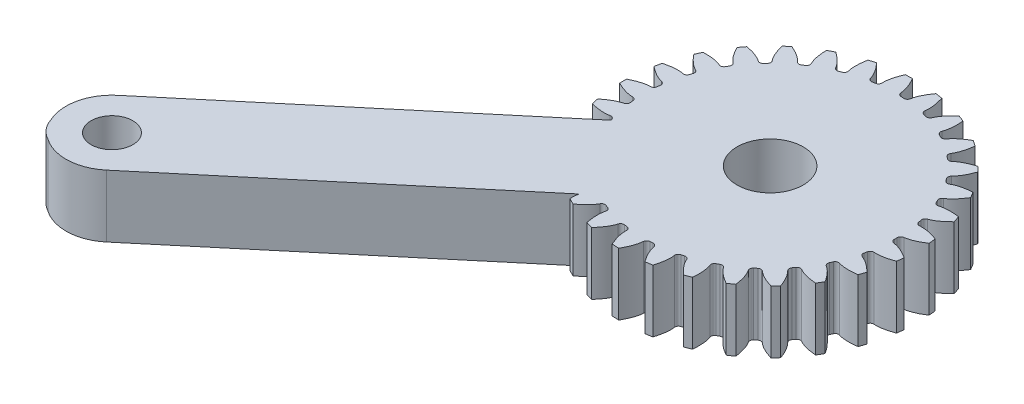
from build123d import *

# Parameters (mm, degrees)
BOSS_EXTRUDE1_DEPTH   = 5.08
CUT_EXTRUDE1_DEPTH    = 6.0800001
CUT_EXTRUDE2_DEPTH    = 6.0800001
CUT_EXTRUDE3_DEPTH    = 6.0800001
CUT_EXTRUDE4_DEPTH    = 6.0800001
CUT_EXTRUDE5_DEPTH    = 6.0800001
CUT_EXTRUDE6_DEPTH    = 6.0800001
CUT_EXTRUDE7_DEPTH    = 6.0800001
CUT_EXTRUDE8_DEPTH    = 6.0800001
CUT_EXTRUDE9_DEPTH    = 6.0800001
CUT_EXTRUDE10_DEPTH   = 6.0800001
CUT_EXTRUDE11_DEPTH   = 6.0800001
CUT_EXTRUDE12_DEPTH   = 6.0800001
CUT_EXTRUDE13_DEPTH   = 6.0800001
CUT_EXTRUDE14_DEPTH   = 6.0800001
CUT_EXTRUDE15_DEPTH   = 6.0800001
CUT_EXTRUDE16_DEPTH   = 6.0800001
CUT_EXTRUDE17_DEPTH   = 6.0800001
CUT_EXTRUDE18_DEPTH   = 6.0800001
CUT_EXTRUDE19_DEPTH   = 6.0800001
CUT_EXTRUDE20_DEPTH   = 6.0800001
CUT_EXTRUDE21_DEPTH   = 6.0800001
CUT_EXTRUDE22_DEPTH   = 6.0800001
CUT_EXTRUDE23_DEPTH   = 6.0800001
CUT_EXTRUDE24_DEPTH   = 6.0800001
CUT_EXTRUDE25_DEPTH   = 6.0800001
CUT_EXTRUDE26_DEPTH   = 6.0800001
F_3_0MM_DOWEL_HOLE1_D = 3.4
FILLET1_R             = 0.285695909
SKETCH32_R            = 2.7
CUT_EXTRUDE27_DEPTH   = 10
SKETCH33_R            = 1.7
BOSS_EXTRUDE2_DEPTH   = 5.08


with BuildPart() as part:
    # Sketch1 → Boss-Extrude1 (new body)
    with BuildSketch(Plane.XZ.offset(5.08)):
        with BuildLine():
            Line((120.988344105, 8.360112759), (98.473510803, 27.252301079))
            ThreePointArc((98.473510803, 27.252301079), (94.895077389, 26.939228722), (95.208149746, 23.360795308))
            Line((95.208149746, 23.360795308), (116.748790674, 5.28605145))
            ThreePointArc((116.748790674, 5.28605145), (116.495793982, 5.294008336), (116.242709511, 5.289662267))
            ThreePointArc((116.242709511, 5.289662267), (135.702860946, -8.243787778), (121.135707512, 10.455137454))
            add(Edge.make_bspline(
                [(121.135707512, 10.455137454), (121.152351035, 9.20992249), (121.586653527, 8.700816936)],
                knots=[1.711217129, 1.711217129, 1.711217129, 2.740480077, 2.740480077, 2.740480077], degree=2, weights=[1, 0.870474175, 1]))
            ThreePointArc((121.586653527, 8.700816936), (121.364900681, 8.558866224), (121.146868004, 8.411265138))
            ThreePointArc((121.146868004, 8.411265138), (121.071416809, 8.373879223), (120.988344105, 8.360112759))
        make_face()
    extrude(amount=-BOSS_EXTRUDE1_DEPTH)

    # Sketch2 → Cut-Extrude1 (cut, through all)
    with BuildSketch(Plane(origin=(0, 0, 0), x_dir=(-1, 0, 0), z_dir=(0, 1, 0))):
        with BuildLine():
            ThreePointArc((-115.357087959, 2.85349343), (-115.640020682, 3.827622688), (-116.004297812, 4.774343824))
            add(Edge.make_bspline(
                [(-117.42496235, 3.650642325), (-116.771119594, 3.793109057), (-116.004297812, 4.774343824)],
                knots=[3.54270523, 3.54270523, 3.54270523, 4.571968178, 4.571968178, 4.571968178], degree=2, weights=[1, 0.870474175, 1]))
            ThreePointArc((-117.42496235, 3.650642325), (-117.289049937, 3.27200004), (-117.168104319, 2.888314855))
            add(Edge.make_bspline(
                [(-115.357087959, 2.85349343), (-116.561367441, 3.170586854), (-117.168104319, 2.888314855)],
                knots=[4.852809783, 4.852809783, 4.852809783, 5.882072731, 5.882072731, 5.882072731], degree=2, weights=[1, 0.870474175, 1]))
        make_face()
    extrude(amount=-CUT_EXTRUDE1_DEPTH, mode=Mode.SUBTRACT)

    # Sketch3 → Cut-Extrude2 (cut, through all)
    with BuildSketch(Plane(origin=(0, 0, 0), x_dir=(-1, 0, 0), z_dir=(0, 1, 0))):
        with BuildLine():
            ThreePointArc((-115.015876033, 0.283898413), (-115.082784951, 1.296075242), (-115.235028425, 2.298971379))
            add(Edge.make_bspline(
                [(-116.864041222, 1.506942278), (-116.194858809, 1.505521352), (-115.235028425, 2.298971379)],
                knots=[0.401112576, 0.401112576, 0.401112576, 1.430375524, 1.430375524, 1.430375524], degree=2, weights=[1, 0.870474175, 1]))
            ThreePointArc((-116.864041222, 1.506942278), (-116.812703264, 1.107935288), (-116.777066261, 0.707220716))
            add(Edge.make_bspline(
                [(-115.015876033, 0.283898413), (-116.123834418, 0.852462859), (-116.777066261, 0.707220716)],
                knots=[4.852809783, 4.852809783, 4.852809783, 5.882072731, 5.882072731, 5.882072731], degree=2, weights=[1, 0.870474175, 1]))
        make_face()
    extrude(amount=-CUT_EXTRUDE2_DEPTH, mode=Mode.SUBTRACT)

    # Sketch4 → Cut-Extrude3 (cut, through all)
    with BuildSketch(Plane(origin=(0, 0, 0), x_dir=(-1, 0, 0), z_dir=(0, 1, 0))):
        with BuildLine():
            ThreePointArc((-115.235028425, -2.298971379), (-115.082784951, -1.296075242), (-115.015876033, -0.283898413))
            add(Edge.make_bspline(
                [(-116.777066261, -0.707220716), (-116.123834418, -0.852462859), (-115.015876033, -0.283898413)],
                knots=[0.401112576, 0.401112576, 0.401112576, 1.430375524, 1.430375524, 1.430375524], degree=2, weights=[1, 0.870474175, 1]))
            ThreePointArc((-116.777066261, -0.707220716), (-116.812703264, -1.107935288), (-116.864041222, -1.506942278))
            add(Edge.make_bspline(
                [(-115.235028425, -2.298971379), (-116.194858809, -1.505521352), (-116.864041222, -1.506942278)],
                knots=[4.852809783, 4.852809783, 4.852809783, 5.882072731, 5.882072731, 5.882072731], degree=2, weights=[1, 0.870474175, 1]))
        make_face()
    extrude(amount=-CUT_EXTRUDE3_DEPTH, mode=Mode.SUBTRACT)

    # Sketch5 → Cut-Extrude4 (cut, through all)
    with BuildSketch(Plane(origin=(0, 0, 0), x_dir=(-1, 0, 0), z_dir=(0, 1, 0))):
        with BuildLine():
            ThreePointArc((-116.004297812, -4.774343824), (-115.640020682, -3.827622688), (-115.357087959, -2.85349343))
            add(Edge.make_bspline(
                [(-117.168104319, -2.888314855), (-116.561367441, -3.170586854), (-115.357087959, -2.85349343)],
                knots=[0.401112576, 0.401112576, 0.401112576, 1.430375524, 1.430375524, 1.430375524], degree=2, weights=[1, 0.870474175, 1]))
            ThreePointArc((-117.168104319, -2.888314855), (-117.289049937, -3.27200004), (-117.42496235, -3.650642325))
            add(Edge.make_bspline(
                [(-116.004297812, -4.774343824), (-116.771119594, -3.793109057), (-117.42496235, -3.650642325)],
                knots=[1.711217129, 1.711217129, 1.711217129, 2.740480077, 2.740480077, 2.740480077], degree=2, weights=[1, 0.870474175, 1]))
        make_face()
    extrude(amount=-CUT_EXTRUDE4_DEPTH, mode=Mode.SUBTRACT)

    # Sketch6 → Cut-Extrude5 (cut, through all)
    with BuildSketch(Plane(origin=(0, 0, 0), x_dir=(-1, 0, 0), z_dir=(0, 1, 0))):
        with BuildLine():
            ThreePointArc((-117.287714012, -7.026473259), (-116.728436419, -6.180194752), (-116.242709511, -5.289662267))
            add(Edge.make_bspline(
                [(-118.018870892, -4.934354601), (-117.486999322, -5.340457732), (-116.242709511, -5.289662267)],
                knots=[0.401112576, 0.401112576, 0.401112576, 1.430375524, 1.430375524, 1.430375524], degree=2, weights=[1, 0.870474175, 1]))
            ThreePointArc((-118.018870892, -4.934354601), (-118.219469842, -5.283069707), (-118.433601597, -5.623642395))
            add(Edge.make_bspline(
                [(-117.287714012, -7.026473259), (-117.825671457, -5.903335199), (-118.433601597, -5.623642395)],
                knots=[1.711217129, 1.711217129, 1.711217129, 2.740480077, 2.740480077, 2.740480077], degree=2, weights=[1, 0.870474175, 1]))
        make_face()
    extrude(amount=-CUT_EXTRUDE5_DEPTH, mode=Mode.SUBTRACT)

    # Sketch7 → Cut-Extrude6 (cut, through all)
    with BuildSketch(Plane(origin=(0, 0, 0), x_dir=(-1, 0, 0), z_dir=(0, 1, 0))):
        with BuildLine():
            ThreePointArc((-119.025265911, -8.950052613), (-118.297139054, -8.243787777), (-117.631330011, -7.478492374))
            add(Edge.make_bspline(
                [(-119.289585081, -6.74966941), (-118.857448541, -7.260614741), (-117.631330011, -7.478492374)],
                knots=[0.401112576, 0.401112576, 0.401112576, 1.430375524, 1.430375524, 1.430375524], degree=2, weights=[1, 0.870474175, 1]))
            ThreePointArc((-119.289585081, -6.74966941), (-119.560457579, -7.047108907), (-119.842796113, -7.333687197))
            add(Edge.make_bspline(
                [(-119.025265911, -8.950052613), (-119.309204727, -7.737527949), (-119.842796113, -7.333687197)],
                knots=[1.711217129, 1.711217129, 1.711217129, 2.740480077, 2.740480077, 2.740480077], degree=2, weights=[1, 0.870474175, 1]))
        make_face()
    extrude(amount=-CUT_EXTRUDE6_DEPTH, mode=Mode.SUBTRACT)

    # Sketch8 → Cut-Extrude7 (cut, through all)
    with BuildSketch(Plane(origin=(0, 0, 0), x_dir=(-1, 0, 0), z_dir=(0, 1, 0))):
        with BuildLine():
            ThreePointArc((-121.135707512, -10.455137454), (-120.272777795, -9.921910449), (-119.458019107, -9.31763649))
            add(Edge.make_bspline(
                [(-120.920829701, -8.24937718), (-120.608634416, -8.841273475), (-119.458019107, -9.31763649)],
                knots=[0.401112577, 0.401112577, 0.401112577, 1.430375524, 1.430375524, 1.430375524], degree=2, weights=[1, 0.870474175, 1]))
            ThreePointArc((-120.920829701, -8.24937718), (-121.24931005, -8.481633126), (-121.586653527, -8.700816936))
            add(Edge.make_bspline(
                [(-121.135707512, -10.455137454), (-121.152351035, -9.20992249), (-121.586653527, -8.700816936)],
                knots=[1.711217129, 1.711217129, 1.711217129, 2.740480077, 2.740480077, 2.740480077], degree=2, weights=[1, 0.870474175, 1]))
        make_face()
    extrude(amount=-CUT_EXTRUDE7_DEPTH, mode=Mode.SUBTRACT)

    # Sketch9 → Cut-Extrude8 (cut, through all)
    with BuildSketch(Plane(origin=(0, 0, 0), x_dir=(-1, 0, 0), z_dir=(0, 1, 0))):
        with BuildLine():
            ThreePointArc((-123.520356913, -11.471351688), (-122.562973968, -11.136095615), (-121.637362847, -10.72109828))
            add(Edge.make_bspline(
                [(-122.836329568, -9.363353241), (-122.658673443, -10.008524088), (-121.637362847, -10.72109828)],
                knots=[0.401112577, 0.401112577, 0.401112577, 1.430375524, 1.430375524, 1.430375524], degree=2, weights=[1, 0.870474175, 1]))
            ThreePointArc((-122.836329568, -9.363353241), (-123.207058392, -9.519565607), (-123.583633006, -9.661106145))
            add(Edge.make_bspline(
                [(-123.520356913, -11.471351688), (-123.268926911, -10.251671293), (-123.583633006, -9.661106145)],
                knots=[1.711217129, 1.711217129, 1.711217129, 2.740480077, 2.740480077, 2.740480077], degree=2, weights=[1, 0.870474175, 1]))
        make_face()
    extrude(amount=-CUT_EXTRUDE8_DEPTH, mode=Mode.SUBTRACT)

    # Sketch10 → Cut-Extrude9 (cut, through all)
    with BuildSketch(Plane(origin=(0, 0, 0), x_dir=(-1, 0, 0), z_dir=(0, 1, 0))):
        with BuildLine():
            ThreePointArc((-126.067710557, -11.951178266), (-125.060640548, -11.829569328), (-124.06745754, -11.623253429))
            add(Edge.make_bspline(
                [(-124.946518037, -10.039509311), (-124.911708074, -10.707787237), (-124.06745754, -11.623253429)],
                knots=[0.401112576, 0.401112576, 0.401112576, 1.430375524, 1.430375524, 1.430375524], degree=2, weights=[1, 0.870474175, 1]))
            ThreePointArc((-124.946518037, -10.039509311), (-125.342160468, -10.11237378), (-125.740358009, -10.169652769))
            add(Edge.make_bspline(
                [(-126.067710557, -11.951178266), (-125.559963617, -10.814063339), (-125.740358009, -10.169652769)],
                knots=[1.711217129, 1.711217129, 1.711217129, 2.740480077, 2.740480077, 2.740480077], degree=2, weights=[1, 0.870474175, 1]))
        make_face()
    extrude(amount=-CUT_EXTRUDE9_DEPTH, mode=Mode.SUBTRACT)

    # Sketch11 → Cut-Extrude10 (cut, through all)
    with BuildSketch(Plane(origin=(0, 0, 0), x_dir=(-1, 0, 0), z_dir=(0, 1, 0))):
        with BuildLine():
            ThreePointArc((-128.658657019, -11.872181032), (-127.64898942, -11.969905526), (-126.634674659, -11.981918167))
            add(Edge.make_bspline(
                [(-127.15272504, -10.246229084), (-127.262388915, -10.906366157), (-126.634674659, -11.981918167)],
                knots=[0.401112576, 0.401112576, 0.401112576, 1.430375524, 1.430375524, 1.430375524], degree=2, weights=[1, 0.870474175, 1]))
            ThreePointArc((-127.15272504, -10.246229084), (-127.554781278, -10.232338595), (-127.955982471, -10.202677732))
            add(Edge.make_bspline(
                [(-128.658657019, -11.872181032), (-127.918334824, -10.870801803), (-127.955982471, -10.202677732)],
                knots=[1.711217129, 1.711217129, 1.711217129, 2.740480077, 2.740480077, 2.740480077], degree=2, weights=[1, 0.870474175, 1]))
        make_face()
    extrude(amount=-CUT_EXTRUDE10_DEPTH, mode=Mode.SUBTRACT)

    # Sketch12 → Cut-Extrude11 (cut, through all)
    with BuildSketch(Plane(origin=(0, 0, 0), x_dir=(-1, 0, 0), z_dir=(0, 1, 0))):
        with BuildLine():
            ThreePointArc((-131.172046522, -11.238053807), (-130.206992268, -11.550542245), (-129.218973986, -11.780321728))
            add(Edge.make_bspline(
                [(-129.351790791, -9.973846573), (-129.600800742, -10.594975516), (-129.218973986, -11.780321728)],
                knots=[0.401112576, 0.401112576, 0.401112576, 1.430375524, 1.430375524, 1.430375524], degree=2, weights=[1, 0.870474175, 1]))
            ThreePointArc((-129.351790791, -9.973846573), (-129.741461132, -9.873850629), (-130.126906256, -9.758636823))
            add(Edge.make_bspline(
                [(-131.172046522, -11.238053807), (-130.233765715, -10.419233657), (-130.126906256, -9.758636823)],
                knots=[1.711217129, 1.711217129, 1.711217129, 2.740480077, 2.740480077, 2.740480077], degree=2, weights=[1, 0.870474175, 1]))
        make_face()
    extrude(amount=-CUT_EXTRUDE11_DEPTH, mode=Mode.SUBTRACT)

    # Sketch13 → Cut-Extrude12 (cut, through all)
    with BuildSketch(Plane(origin=(0, 0, 0), x_dir=(-1, 0, 0), z_dir=(0, 1, 0))):
        with BuildLine():
            ThreePointArc((-133.490355767, -10.078447677), (-132.615039722, -10.591088446), (-131.699516555, -11.027890538))
            add(Edge.make_bspline(
                [(-131.440889417, -9.235098081), (-131.817602016, -9.788175596), (-131.699516555, -11.027890538)],
                knots=[0.401112576, 0.401112576, 0.401112576, 1.430375524, 1.430375524, 1.430375524], degree=2, weights=[1, 0.870474175, 1]))
            ThreePointArc((-131.440889417, -9.235098081), (-131.799953311, -9.053672382), (-132.151619379, -8.858292903))
            add(Edge.make_bspline(
                [(-133.490355767, -10.078447677), (-132.397989315, -9.480473725), (-132.151619379, -8.858292903)],
                knots=[1.711217129, 1.711217129, 1.711217129, 2.740480077, 2.740480077, 2.740480077], degree=2, weights=[1, 0.870474175, 1]))
        make_face()
    extrude(amount=-CUT_EXTRUDE12_DEPTH, mode=Mode.SUBTRACT)

    # Sketch14 → Cut-Extrude13 (cut, through all)
    with BuildSketch(Plane(origin=(0, 0, 0), x_dir=(-1, 0, 0), z_dir=(0, 1, 0))):
        with BuildLine():
            ThreePointArc((-135.50518319, -8.447584535), (-134.760534159, -9.136407123), (-133.960314953, -9.759807443))
            add(Edge.make_bspline(
                [(-133.32233699, -8.064526667), (-133.809137575, -8.523691464), (-133.960314953, -9.759807443)],
                knots=[0.401112576, 0.401112576, 0.401112576, 1.430375524, 1.430375524, 1.430375524], degree=2, weights=[1, 0.870474175, 1]))
            ThreePointArc((-133.32233699, -8.064526667), (-133.634005007, -7.810154476), (-133.935448505, -7.543745052))
            add(Edge.make_bspline(
                [(-135.50518319, -8.447584535), (-134.309808935, -8.098417378), (-133.935448505, -7.543745052)],
                knots=[1.711217129, 1.711217129, 1.711217129, 2.740480077, 2.740480077, 2.740480077], degree=2, weights=[1, 0.870474175, 1]))
        make_face()
    extrude(amount=-CUT_EXTRUDE13_DEPTH, mode=Mode.SUBTRACT)

    # Sketch15 → Cut-Extrude14 (cut, through all)
    with BuildSketch(Plane(origin=(0, 0, 0), x_dir=(-1, 0, 0), z_dir=(0, 1, 0))):
        with BuildLine():
            ThreePointArc((-137.122317699, -6.421721728), (-136.543154645, -7.254517557), (-135.895656759, -8.035366599))
            add(Edge.make_bspline(
                [(-134.908159112, -6.516866949), (-135.482285429, -6.860648992), (-135.895656759, -8.035366599)],
                knots=[0.401112576, 0.401112576, 0.401112576, 1.430375524, 1.430375524, 1.430375524], degree=2, weights=[1, 0.870474175, 1]))
            ThreePointArc((-134.908159112, -6.516866949), (-135.157858003, -6.201442428), (-135.394983768, -5.876460066))
            add(Edge.make_bspline(
                [(-137.122317699, -6.421721728), (-135.879830013, -6.337688035), (-135.394983768, -5.876460066)],
                knots=[1.711217129, 1.711217129, 1.711217129, 2.740480077, 2.740480077, 2.740480077], degree=2, weights=[1, 0.870474175, 1]))
        make_face()
    extrude(amount=-CUT_EXTRUDE14_DEPTH, mode=Mode.SUBTRACT)

    # Sketch16 → Cut-Extrude15 (cut, through all)
    with BuildSketch(Plane(origin=(0, 0, 0), x_dir=(-1, 0, 0), z_dir=(0, 1, 0))):
        with BuildLine():
            ThreePointArc((-138.266143883, -4.095586351), (-137.879547825, -5.033414813), (-137.415047543, -5.935200944))
            add(Edge.make_bspline(
                [(-136.124204504, -4.664485776), (-136.758811043, -4.876810199), (-137.415047543, -5.935200944)],
                knots=[0.401112576, 0.401112576, 0.401112576, 1.430375524, 1.430375524, 1.430375524], degree=2, weights=[1, 0.870474175, 1]))
            ThreePointArc((-136.124204504, -4.664485776), (-136.300258625, -4.302757824), (-136.46197892, -3.934398339))
            add(Edge.make_bspline(
                [(-138.266143883, -4.095586351), (-137.034640109, -4.280615444), (-136.46197892, -3.934398339)],
                knots=[1.711217129, 1.711217129, 1.711217129, 2.740480077, 2.740480077, 2.740480077], degree=2, weights=[1, 0.870474175, 1]))
        make_face()
    extrude(amount=-CUT_EXTRUDE15_DEPTH, mode=Mode.SUBTRACT)

    # Sketch17 → Cut-Extrude16 (cut, through all)
    with BuildSketch(Plane(origin=(0, 0, 0), x_dir=(-1, 0, 0), z_dir=(0, 1, 0))):
        with BuildLine():
            ThreePointArc((-138.883177701, -1.577945908), (-138.707225441, -2.576955187), (-138.447442279, -3.557511889))
            add(Edge.make_bspline(
                [(-136.913612234, -2.593998431), (-137.579025499, -2.664937181), (-138.447442279, -3.557511889)],
                knots=[0.401112576, 0.401112576, 0.401112576, 1.430375524, 1.430375524, 1.430375524], degree=2, weights=[1, 0.870474175, 1]))
            ThreePointArc((-136.913612234, -2.593998431), (-137.00778949, -2.202881047), (-137.086542454, -1.808368519))
            add(Edge.make_bspline(
                [(-138.883177701, -1.577945908), (-137.720241586, -2.023386032), (-137.086542454, -1.808368519)],
                knots=[1.711217129, 1.711217129, 1.711217129, 2.740480077, 2.740480077, 2.740480077], degree=2, weights=[1, 0.870474175, 1]))
        make_face()
    extrude(amount=-CUT_EXTRUDE16_DEPTH, mode=Mode.SUBTRACT)

    # Sketch18 → Cut-Extrude17 (cut, through all)
    with BuildSketch(Plane(origin=(0, 0, 0), x_dir=(-1, 0, 0), z_dir=(0, 1, 0))):
        with BuildLine():
            ThreePointArc((-138.944567336, 1.013477532), (-138.987486207, 0), (-138.944567336, -1.013477532))
            add(Edge.make_bspline(
                [(-137.239470473, -0.402218604), (-137.904576481, -0.328454662), (-138.944567336, -1.013477532)],
                knots=[3.54270523, 3.54270523, 3.54270523, 4.571968178, 4.571968178, 4.571968178], degree=2, weights=[1, 0.870474175, 1]))
            ThreePointArc((-137.239470473, -0.402218604), (-137.247367241, 0), (-137.239470473, 0.402218604))
            add(Edge.make_bspline(
                [(-138.944567336, 1.013477532), (-137.904576481, 0.328454662), (-137.239470473, 0.402218604)],
                knots=[1.711217129, 1.711217129, 1.711217129, 2.740480077, 2.740480077, 2.740480077], degree=2, weights=[1, 0.870474175, 1]))
        make_face()
    extrude(amount=-CUT_EXTRUDE17_DEPTH, mode=Mode.SUBTRACT)

    # Sketch19 → Cut-Extrude18 (cut, through all)
    with BuildSketch(Plane(origin=(0, 0, 0), x_dir=(-1, 0, 0), z_dir=(0, 1, 0))):
        with BuildLine():
            ThreePointArc((-138.447442279, 3.557511889), (-138.707225441, 2.576955187), (-138.883177701, 1.577945908))
            add(Edge.make_bspline(
                [(-137.086542454, 1.808368519), (-137.720241586, 2.023386032), (-138.883177701, 1.577945908)],
                knots=[3.54270523, 3.54270523, 3.54270523, 4.571968178, 4.571968178, 4.571968178], degree=2, weights=[1, 0.870474175, 1]))
            ThreePointArc((-137.086542454, 1.808368519), (-137.00778949, 2.202881047), (-136.913612234, 2.593998431))
            add(Edge.make_bspline(
                [(-138.447442279, 3.557511889), (-137.579025499, 2.664937181), (-136.913612234, 2.593998431)],
                knots=[4.852809783, 4.852809783, 4.852809783, 5.882072731, 5.882072731, 5.882072731], degree=2, weights=[1, 0.870474175, 1]))
        make_face()
    extrude(amount=-CUT_EXTRUDE18_DEPTH, mode=Mode.SUBTRACT)

    # Sketch20 → Cut-Extrude19 (cut, through all)
    with BuildSketch(Plane(origin=(0, 0, 0), x_dir=(-1, 0, 0), z_dir=(0, 1, 0))):
        with BuildLine():
            ThreePointArc((-137.415047543, 5.935200944), (-137.879547825, 5.033414813), (-138.266143883, 4.095586351))
            add(Edge.make_bspline(
                [(-136.46197892, 3.934398339), (-137.034640109, 4.280615444), (-138.266143883, 4.095586351)],
                knots=[3.54270523, 3.54270523, 3.54270523, 4.571968178, 4.571968178, 4.571968178], degree=2, weights=[1, 0.870474175, 1]))
            ThreePointArc((-136.46197892, 3.934398339), (-136.300258625, 4.302757824), (-136.124204504, 4.664485776))
            add(Edge.make_bspline(
                [(-137.415047543, 5.935200944), (-136.758811043, 4.876810199), (-136.124204504, 4.664485776)],
                knots=[4.852809783, 4.852809783, 4.852809783, 5.882072731, 5.882072731, 5.882072731], degree=2, weights=[1, 0.870474175, 1]))
        make_face()
    extrude(amount=-CUT_EXTRUDE19_DEPTH, mode=Mode.SUBTRACT)

    # Sketch21 → Cut-Extrude20 (cut, through all)
    with BuildSketch(Plane(origin=(0, 0, 0), x_dir=(-1, 0, 0), z_dir=(0, 1, 0))):
        with BuildLine():
            ThreePointArc((-135.895656759, 8.035366599), (-136.543154645, 7.254517557), (-137.122317699, 6.421721728))
            add(Edge.make_bspline(
                [(-135.394983768, 5.876460066), (-135.879830013, 6.337688035), (-137.122317699, 6.421721728)],
                knots=[3.54270523, 3.54270523, 3.54270523, 4.571968178, 4.571968178, 4.571968178], degree=2, weights=[1, 0.870474175, 1]))
            ThreePointArc((-135.394983768, 5.876460066), (-135.157858003, 6.201442428), (-134.908159112, 6.516866949))
            add(Edge.make_bspline(
                [(-135.895656759, 8.035366599), (-135.482285429, 6.860648992), (-134.908159112, 6.516866949)],
                knots=[4.852809783, 4.852809783, 4.852809783, 5.882072731, 5.882072731, 5.882072731], degree=2, weights=[1, 0.870474175, 1]))
        make_face()
    extrude(amount=-CUT_EXTRUDE20_DEPTH, mode=Mode.SUBTRACT)

    # Sketch22 → Cut-Extrude21 (cut, through all)
    with BuildSketch(Plane(origin=(0, 0, 0), x_dir=(-1, 0, 0), z_dir=(0, 1, 0))):
        with BuildLine():
            ThreePointArc((-133.960314953, 9.759807443), (-134.760534159, 9.136407123), (-135.50518319, 8.447584535))
            add(Edge.make_bspline(
                [(-133.935448505, 7.543745052), (-134.309808935, 8.098417378), (-135.50518319, 8.447584535)],
                knots=[3.54270523, 3.54270523, 3.54270523, 4.571968178, 4.571968178, 4.571968178], degree=2, weights=[1, 0.870474175, 1]))
            ThreePointArc((-133.935448505, 7.543745052), (-133.634005007, 7.810154476), (-133.32233699, 8.064526667))
            add(Edge.make_bspline(
                [(-133.960314953, 9.759807443), (-133.809137575, 8.523691464), (-133.32233699, 8.064526667)],
                knots=[4.852809783, 4.852809783, 4.852809783, 5.882072731, 5.882072731, 5.882072731], degree=2, weights=[1, 0.870474175, 1]))
        make_face()
    extrude(amount=-CUT_EXTRUDE21_DEPTH, mode=Mode.SUBTRACT)

    # Sketch23 → Cut-Extrude22 (cut, through all)
    with BuildSketch(Plane(origin=(0, 0, 0), x_dir=(-1, 0, 0), z_dir=(0, 1, 0))):
        with BuildLine():
            ThreePointArc((-131.699516555, 11.027890538), (-132.615039722, 10.591088446), (-133.490355767, 10.078447677))
            add(Edge.make_bspline(
                [(-132.151619379, 8.858292903), (-132.397989315, 9.480473725), (-133.490355767, 10.078447677)],
                knots=[3.54270523, 3.54270523, 3.54270523, 4.571968178, 4.571968178, 4.571968178], degree=2, weights=[1, 0.870474175, 1]))
            ThreePointArc((-132.151619379, 8.858292903), (-131.799953311, 9.053672382), (-131.440889417, 9.235098081))
            add(Edge.make_bspline(
                [(-131.699516555, 11.027890538), (-131.817602016, 9.788175596), (-131.440889417, 9.235098081)],
                knots=[4.852809783, 4.852809783, 4.852809783, 5.882072731, 5.882072731, 5.882072731], degree=2, weights=[1, 0.870474175, 1]))
        make_face()
    extrude(amount=-CUT_EXTRUDE22_DEPTH, mode=Mode.SUBTRACT)

    # Sketch24 → Cut-Extrude23 (cut, through all)
    with BuildSketch(Plane(origin=(0, 0, 0), x_dir=(-1, 0, 0), z_dir=(0, 1, 0))):
        with BuildLine():
            ThreePointArc((-129.218973986, 11.780321728), (-130.206992268, 11.550542245), (-131.172046522, 11.238053807))
            add(Edge.make_bspline(
                [(-130.126906256, 9.758636823), (-130.233765715, 10.419233657), (-131.172046522, 11.238053807)],
                knots=[3.54270523, 3.54270523, 3.54270523, 4.571968178, 4.571968178, 4.571968178], degree=2, weights=[1, 0.870474175, 1]))
            ThreePointArc((-130.126906256, 9.758636823), (-129.741461132, 9.873850629), (-129.351790791, 9.973846573))
            add(Edge.make_bspline(
                [(-129.218973986, 11.780321728), (-129.600800742, 10.594975516), (-129.351790791, 9.973846573)],
                knots=[4.852809783, 4.852809783, 4.852809783, 5.882072731, 5.882072731, 5.882072731], degree=2, weights=[1, 0.870474175, 1]))
        make_face()
    extrude(amount=-CUT_EXTRUDE23_DEPTH, mode=Mode.SUBTRACT)

    # Sketch25 → Cut-Extrude24 (cut, through all)
    with BuildSketch(Plane(origin=(0, 0, 0), x_dir=(-1, 0, 0), z_dir=(0, 1, 0))):
        with BuildLine():
            ThreePointArc((-126.634674659, 11.981918167), (-127.64898942, 11.969905526), (-128.658657019, 11.872181032))
            add(Edge.make_bspline(
                [(-127.955982471, 10.202677732), (-127.918334824, 10.870801803), (-128.658657019, 11.872181032)],
                knots=[3.54270523, 3.54270523, 3.54270523, 4.571968178, 4.571968178, 4.571968178], degree=2, weights=[1, 0.870474175, 1]))
            ThreePointArc((-127.955982471, 10.202677732), (-127.554781278, 10.232338595), (-127.15272504, 10.246229084))
            add(Edge.make_bspline(
                [(-126.634674659, 11.981918167), (-127.262388915, 10.906366157), (-127.15272504, 10.246229084)],
                knots=[4.852809783, 4.852809783, 4.852809783, 5.882072731, 5.882072731, 5.882072731], degree=2, weights=[1, 0.870474175, 1]))
        make_face()
    extrude(amount=-CUT_EXTRUDE24_DEPTH, mode=Mode.SUBTRACT)

    # Sketch26 → Cut-Extrude25 (cut, through all)
    with BuildSketch(Plane(origin=(0, 0, 0), x_dir=(-1, 0, 0), z_dir=(0, 1, 0))):
        with BuildLine():
            ThreePointArc((-124.06745754, 11.623253429), (-125.060640548, 11.829569328), (-126.067710557, 11.951178266))
            add(Edge.make_bspline(
                [(-125.740358009, 10.169652769), (-125.559963617, 10.814063339), (-126.067710557, 11.951178266)],
                knots=[3.54270523, 3.54270523, 3.54270523, 4.571968178, 4.571968178, 4.571968178], degree=2, weights=[1, 0.870474175, 1]))
            ThreePointArc((-125.740358009, 10.169652769), (-125.342160468, 10.11237378), (-124.946518037, 10.039509311))
            add(Edge.make_bspline(
                [(-124.06745754, 11.623253429), (-124.911708074, 10.707787237), (-124.946518037, 10.039509311)],
                knots=[4.852809783, 4.852809783, 4.852809783, 5.882072731, 5.882072731, 5.882072731], degree=2, weights=[1, 0.870474175, 1]))
        make_face()
    extrude(amount=-CUT_EXTRUDE25_DEPTH, mode=Mode.SUBTRACT)

    # Sketch27 → Cut-Extrude26 (cut, through all)
    with BuildSketch(Plane(origin=(0, 0, 0), x_dir=(-1, 0, 0), z_dir=(0, 1, 0))):
        with BuildLine():
            ThreePointArc((-121.637362847, 10.72109828), (-122.562973968, 11.136095615), (-123.520356913, 11.471351688))
            add(Edge.make_bspline(
                [(-123.583633006, 9.661106145), (-123.268926911, 10.251671293), (-123.520356913, 11.471351688)],
                knots=[3.54270523, 3.54270523, 3.54270523, 4.571968178, 4.571968178, 4.571968178], degree=2, weights=[1, 0.870474175, 1]))
            ThreePointArc((-123.583633006, 9.661106145), (-123.207058392, 9.519565607), (-122.836329568, 9.363353241))
            add(Edge.make_bspline(
                [(-121.637362847, 10.72109828), (-122.658673442, 10.008524088), (-122.836329568, 9.363353241)],
                knots=[4.852809783, 4.852809783, 4.852809783, 5.882072731, 5.882072731, 5.882072731], degree=2, weights=[1, 0.870474175, 1]))
        make_face()
    extrude(amount=-CUT_EXTRUDE26_DEPTH, mode=Mode.SUBTRACT)

    # Ø3.0mm Dowel Hole1 (through all)
    with Locations(Plane(origin=(0, -5.08, 0), x_dir=(-1, 0, 0), z_dir=(0, -1, 0))):
        with Locations((-97.813706717, -24.490207929)):
            Hole(F_3_0MM_DOWEL_HOLE1_D / 2)

    # Fillet1
    fillet1_edges = [part.edges().sort_by_distance(p)[0] for p in [
        (116.777066261, -2.54, 0.707220716),
        (131.440889417, -2.54, 9.235098081),
        (136.913612234, -2.54, 2.593998431),
        (137.239470473, -2.54, 0.402218604),
        (117.42496235, -2.54, -3.650642325),
        (122.836329568, -2.54, -9.363353241),
        (122.836329568, -2.54, 9.363353241),
        (123.583633006, -2.54, -9.661106145),
        (133.32233699, -2.54, 8.064526667),
        (120.920829701, -2.54, -8.24937718),
        (127.15272504, -2.54, 10.246229084),
        (121.586653527, -2.54, -8.700816936),
        (116.864041222, -2.54, -1.506942278),
        (118.018870892, -2.54, -4.934354601),
        (117.168104319, -2.54, 2.888314855),
        (118.433601597, -2.54, -5.623642395),
        (119.289585081, -2.54, -6.74966941),
        (136.124204504, -2.54, 4.664485776),
        (119.842796113, -2.54, -7.333687197),
        (134.908159112, -2.54, 6.516866949),
        (124.946518037, -2.54, -10.039509311),
        (129.351790791, -2.54, 9.973846573),
        (125.740358009, -2.54, -10.169652769),
        (124.946518037, -2.54, 10.039509311),
        (127.15272504, -2.54, -10.246229084),
        (116.777066261, -2.54, -0.707220716),
        (127.955982471, -2.54, -10.202677732),
        (116.864041222, -2.54, 1.506942278),
        (129.351790791, -2.54, -9.973846573),
        (117.42496235, -2.54, 3.650642325),
        (130.126906256, -2.54, -9.758636823),
        (123.583633006, -2.54, 9.661106145),
        (131.440889417, -2.54, -9.235098081),
        (121.586653527, -2.54, 8.700816936),
        (132.151619379, -2.54, -8.858292903),
        (137.086542454, -2.54, 1.808368519),
        (134.908159112, -2.54, -6.516866949),
        (136.46197892, -2.54, 3.934398339),
        (135.394983768, -2.54, -5.876460066),
        (133.935448505, -2.54, 7.543745052),
        (133.32233699, -2.54, -8.064526667),
        (135.394983768, -2.54, 5.876460066),
        (133.935448505, -2.54, -7.543745052),
        (132.151619379, -2.54, 8.858292903),
        (136.124204504, -2.54, -4.664485776),
        (130.126906256, -2.54, 9.758636823),
        (136.46197892, -2.54, -3.934398339),
        (127.955982471, -2.54, 10.202677732),
        (136.913612234, -2.54, -2.593998431),
        (125.740358009, -2.54, 10.169652769),
        (137.086542454, -2.54, -1.808368519),
        (137.239470473, -2.54, -0.402218604),
        (117.168104319, -2.54, -2.888314855),
    ]]
    fillet(fillet1_edges, radius=FILLET1_R)

    # Sketch32 → Cut-Extrude27 (cut)
    with BuildSketch(Plane(origin=(0, 0, 0), x_dir=(1, 0, 0), z_dir=(0, 1, 0))):
        with Locations((127, 0)):
            Circle(SKETCH32_R)
    extrude(amount=-CUT_EXTRUDE27_DEPTH, mode=Mode.SUBTRACT)

    # Sketch33 → Boss-Extrude2 (add)
    with BuildSketch(Plane.XZ.offset(5.08)):
        with BuildLine():
            Line((123.884262286, 7.509691702), (100.224160253, 27.362874591))
            ThreePointArc((100.224160253, 27.362874591), (94.941040055, 26.900661465), (95.403253181, 21.617541267))
            Line((95.403253181, 21.617541267), (119.063355213, 1.764358379))
            Line((119.063355213, 1.764358379), (123.884262286, 7.509691702))
        make_face()
        with Locations((97.813706717, 24.490207929)):
            Circle(SKETCH33_R, mode=Mode.SUBTRACT)
    extrude(amount=-BOSS_EXTRUDE2_DEPTH)


solid = part.part
